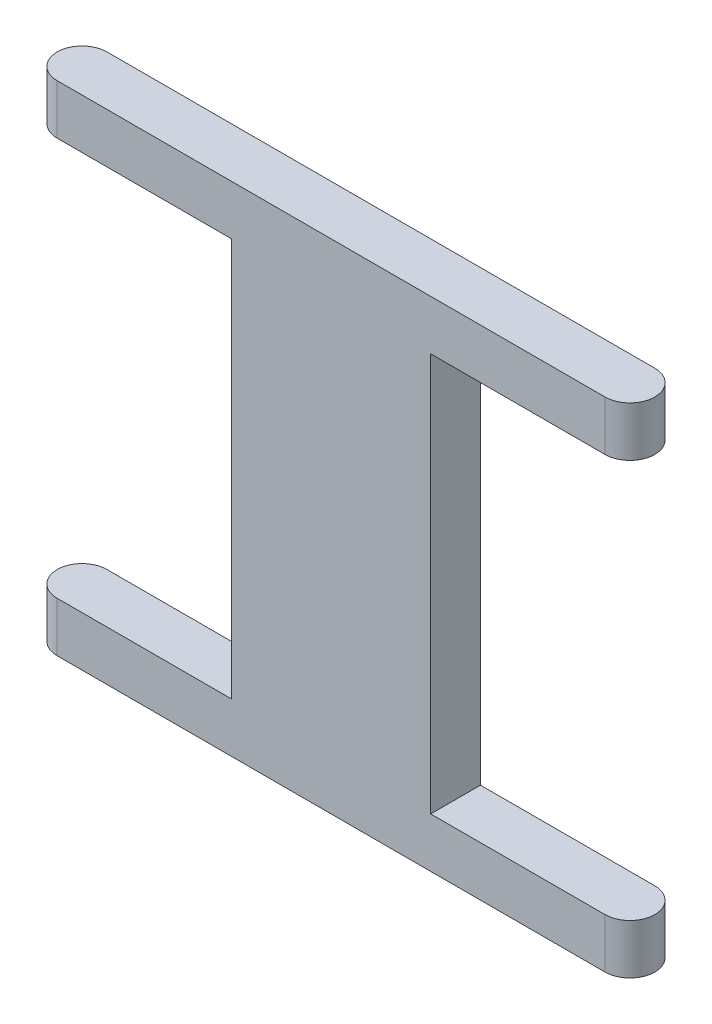
from build123d import *

# Parameters (mm, degrees)
EXTRUDE_1_DEPTH     = 20
SKETCH_2_W          = 8
SKETCH_2_H          = 16
CUT_EXTRUDE_1_DEPTH = 12


with BuildPart() as part:
    # 草图1 → 凸台-拉伸1 (new body)
    with BuildSketch(Plane(origin=(0, 0, 0), x_dir=(1, 0, 0), z_dir=(0, 1, 0))):
        with BuildLine():
            Line((-11, 1), (11, 1))
            ThreePointArc((11, 1), (12, 0), (11, -1))
            Line((11, -1), (-11, -1))
            ThreePointArc((-11, -1), (-12, 0), (-11, 1))
        make_face()
    extrude(amount=EXTRUDE_1_DEPTH)

    # 草图2 → 切除-拉伸1 (cut)
    with BuildSketch(Plane(origin=(0, 0, -1), x_dir=(-1, 0, 0), z_dir=(0, 0, -1))):
        with Locations((-8, 10)):
            Rectangle(SKETCH_2_W, SKETCH_2_H)
        with Locations((8, 10)):
            Rectangle(SKETCH_2_W, SKETCH_2_H)
    extrude(amount=-CUT_EXTRUDE_1_DEPTH, mode=Mode.SUBTRACT)


solid = part.part
